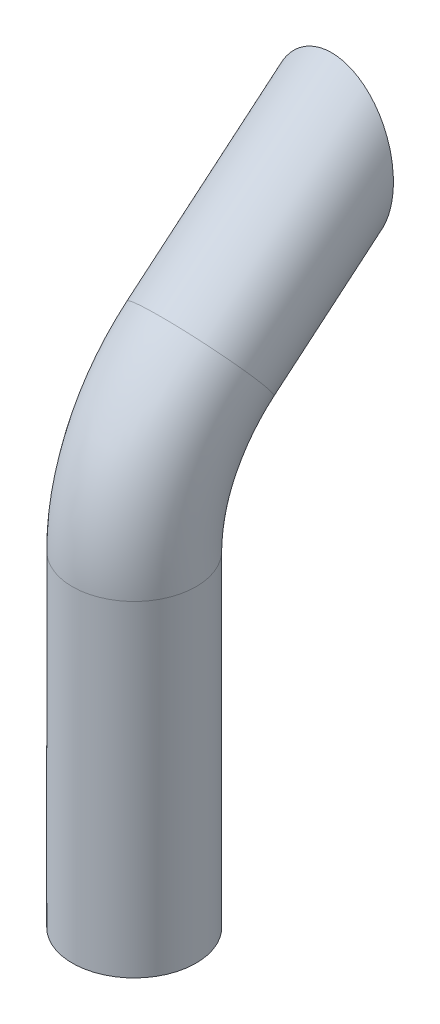
from build123d import *

# Parameters (mm, degrees)
SKETCH2_R          = 30
SKETCH2_R_2        = 27
SKETCH3_W          = 74.646926984
SKETCH3_H          = 102.533071649
CUT_EXTRUDE1_DEPTH = 65


with BuildPart() as part:
    # Sweep-Thin1: sweep along a path in Sketch1
    with BuildLine(Plane(origin=(0, 0, 0), x_dir=(0, 0, -1), z_dir=(1, 0, 0))) as sweep_thin1_path:
        Line((0, 0), (-82.75755134, -69.441830806))
        ThreePointArc((-82.75755134, -69.441830806), (-106.474367301, -100.35018713), (-114.906666468, -138.385830687))
        Line((-114.906666468, -138.385830687), (-114.906666468, -296.418141453))
    # Sketch2 → Sweep-Thin1 (sweep)
    with BuildSketch(Plane(origin=(0, 0, 0), x_dir=(1, 0, 0), z_dir=(0, -0.64278761, 0.766044443))):
        Circle(SKETCH2_R)
        Circle(SKETCH2_R_2, mode=Mode.SUBTRACT)
    sweep(path=sweep_thin1_path.line)

    # Sketch3 → Cut-Extrude1 (cut, symmetric)
    with BuildSketch(Plane(origin=(0, 0, 0), x_dir=(0, 0, -1), z_dir=(1, 0, 0))):
        with Locations((18.039835201, -28.285202531)):
            Rectangle(SKETCH3_W, SKETCH3_H)
    extrude(amount=CUT_EXTRUDE1_DEPTH, both=True, mode=Mode.SUBTRACT)


solid = part.part
